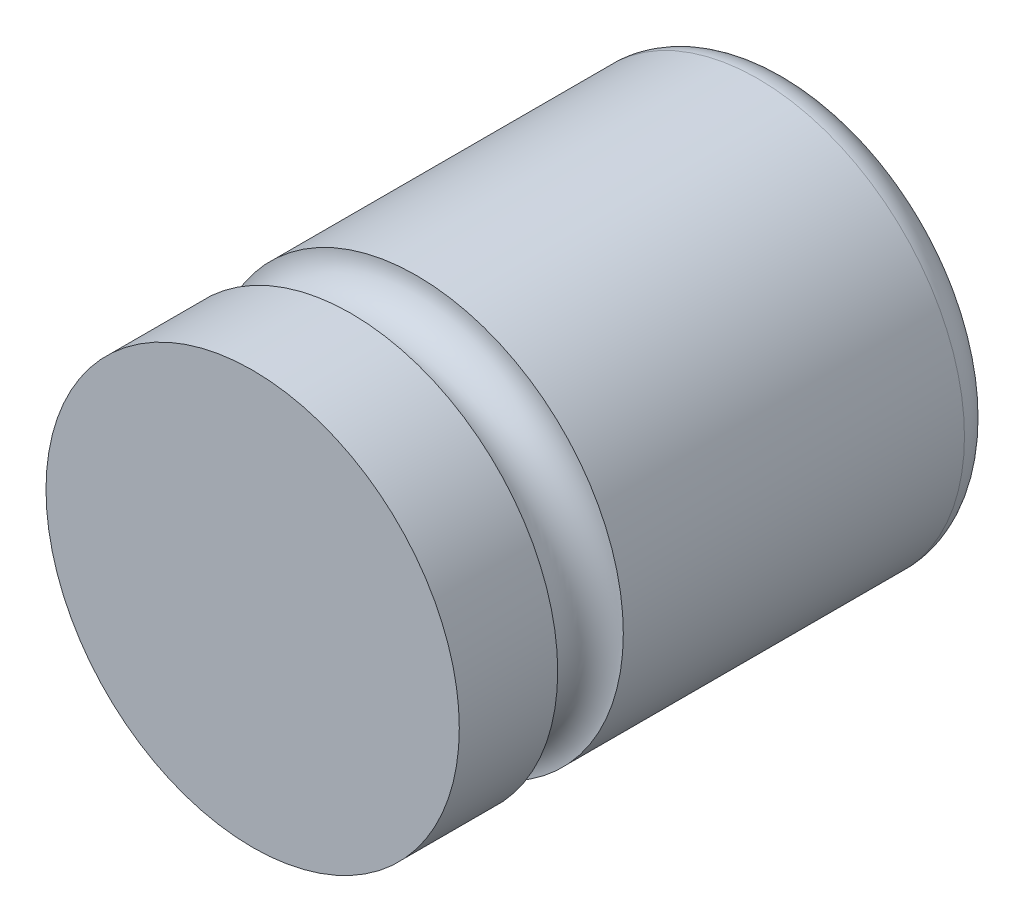
from build123d import *

# Parameters (mm, degrees)
CUT_EXTRUDE1_DEPTH = 0.01


with BuildPart() as part:
    # Sketch1 → Revolve1 (revolve)
    with BuildSketch(Plane(origin=(0, 0, 0), x_dir=(1, 0, 0), z_dir=(0, 1, 0))):
        with BuildLine():
            Line((0, 0), (3.15, 0))
            Line((3.15, 0), (3.15, 1.5))
            ThreePointArc((3.15, 1.5), (2.65, 2), (3.15, 2.5))
            Line((3.15, 2.5), (3.15, 7.7))
            ThreePointArc((3.15, 7.7), (3.003553391, 8.053553391), (2.65, 8.2))
            Line((2.65, 8.2), (0, 8.2))
            Line((0, 8.2), (0, 0))
        make_face()
    revolve(axis=Axis((0, 0, 0), (0, 0, -1)))

    # Sketch2 → Cut-Extrude1 (cut)
    with BuildSketch(Plane(origin=(0, 0, -8.2), x_dir=(-1, 0, 0), z_dir=(0, 0, -1))):
        with BuildLine():
            Line((1.5, 2.184605227), (1.5, -2.184605227))
            ThreePointArc((1.5, -2.184605227), (2.65, 0), (1.5, 2.184605227))
        make_face()
    extrude(amount=-CUT_EXTRUDE1_DEPTH, mode=Mode.SUBTRACT)


solid = part.part
